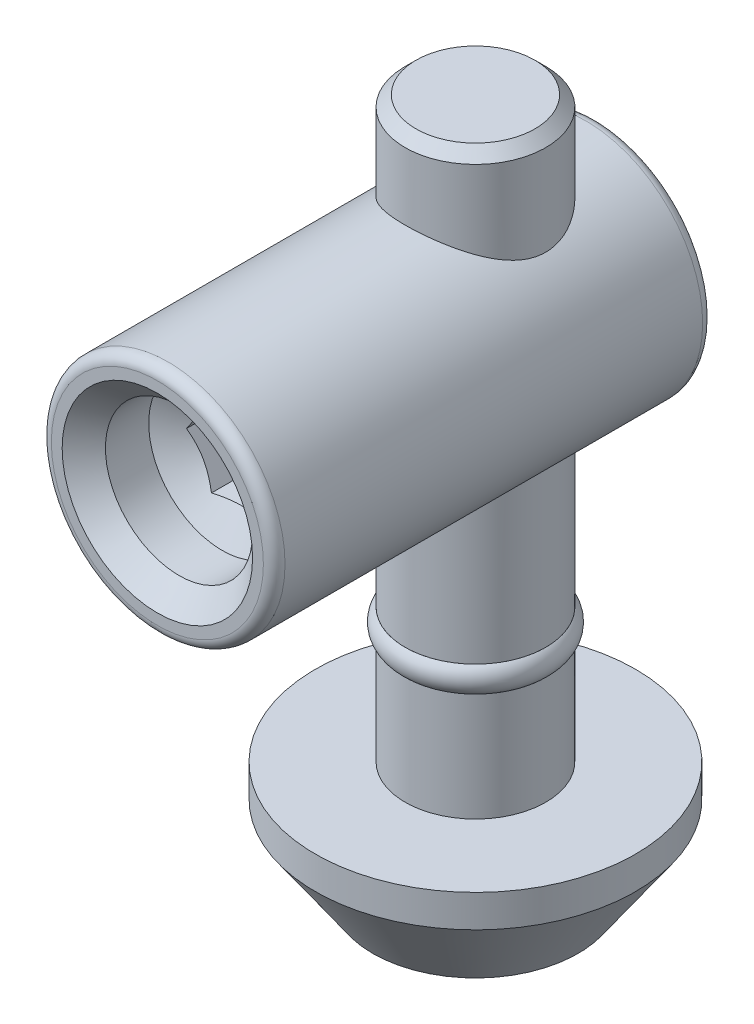
from build123d import *

# Parameters (mm, degrees)
CHAMFER_1_SIZE              = 0.5
SKETCH_12_R                 = 5.4
EXTRUDE_2_DEPTH             = 14.7
EXTRUDE_2_DEPTH_BACK        = 5.6
HOLE_WIZARD_M81_D           = 6.8
HOLE_WIZARD_M81_DEPTH       = 3
HOLE_WIZARD_M81_CSINK_D     = 8.8
HOLE_WIZARD_M81_CSINK_ANGLE = 90
HOLE_WIZARD_M81_TIP         = 2.042926105
FILLET_1_R                  = 0.5
CUT_EXTRUDE_2_DEPTH         = 6


with BuildPart() as part:
    # Эскиз3 → Повернуть1 (revolve)
    with BuildSketch(Plane.XY, mode=Mode.PRIVATE) as revolve_1_sk:
        Polygon((0, 0), (-3.25, 0), (-3.25, -20.5), (-2.75, -20.5), (-2.75, -21.7), (-3.25, -21.7), (-3.25, -26.7), (-7.4, -26.7), (-7.4, -28.2), (-4.75, -32), (0, -32), align=None)
    revolve(revolve_1_sk.sketch.rotate(Axis((0, 0, 0), (0, 1, 0)), 270), axis=Axis((0, 0, 0), (0, 1, 0)))  # turned: the seam where the file's is

    # Фаска1
    chamfer_1_edges = [part.edges().sort_by_distance(p)[0] for p in [
        (0, 0, 3.25),
    ]]
    chamfer(chamfer_1_edges, length=CHAMFER_1_SIZE)

    # Эскиз12 → Бобышка-Вытянуть2 (add, two sides)
    with BuildSketch(Plane.XY) as extrude_2_sk:
        with Locations((0, -9)):
            Circle(SKETCH_12_R)
    extrude(amount=EXTRUDE_2_DEPTH)
    extrude(extrude_2_sk.sketch, amount=-EXTRUDE_2_DEPTH_BACK)

    # Отверстие обработанное метчиком M81
    with Locations(Plane.XY.offset(14.7)):
        with Locations((0, -9)):
            CounterSinkHole(HOLE_WIZARD_M81_D / 2, HOLE_WIZARD_M81_CSINK_D / 2, depth=HOLE_WIZARD_M81_DEPTH, counter_sink_angle=HOLE_WIZARD_M81_CSINK_ANGLE)
            with Locations((0, 0, -(HOLE_WIZARD_M81_DEPTH + HOLE_WIZARD_M81_TIP / 2))):  # 118° drill point
                Cone(0, HOLE_WIZARD_M81_D / 2, HOLE_WIZARD_M81_TIP, mode=Mode.SUBTRACT)

    # Скругление1
    fillet_1_edges = [part.edges().sort_by_distance(p)[0] for p in [
        (-5.4, -9, -5.6),
        (-5.4, -9, 14.7),
    ]]
    fillet(fillet_1_edges, radius=FILLET_1_R)

    # Эскиз15 → Вырез-Вытянуть2 (cut)
    with BuildSketch(Plane.XY.offset(14.7)):
        Polygon((2.309401077, -9), (1.154700538, -7), (-1.154700538, -7), (-2.309401077, -9), (-1.154700538, -11), (1.154700538, -11), align=None)
    extrude(amount=-CUT_EXTRUDE_2_DEPTH, mode=Mode.SUBTRACT)


with BuildPart() as body_2:
    # Эскиз16 → Повернуть2 (revolve)
    with BuildSketch(Plane.XY, mode=Mode.PRIVATE) as revolve_2_sk:
        with BuildLine():
            Line((-2.75, -20.5), (-3.25, -20.5))
            ThreePointArc((-3.25, -20.5), (-3.531024968, -21.1), (-3.25, -21.7))
            Line((-3.25, -21.7), (-2.75, -21.7))
            Line((-2.75, -21.7), (-2.75, -20.5))
        make_face()
    revolve(revolve_2_sk.sketch.rotate(Axis((0, -20.5, 0), (0, -1, 0)), 90), axis=Axis((0, -20.5, 0), (0, -1, 0)))  # turned: the seam where the file's is


solid = Compound([part.part, body_2.part])
